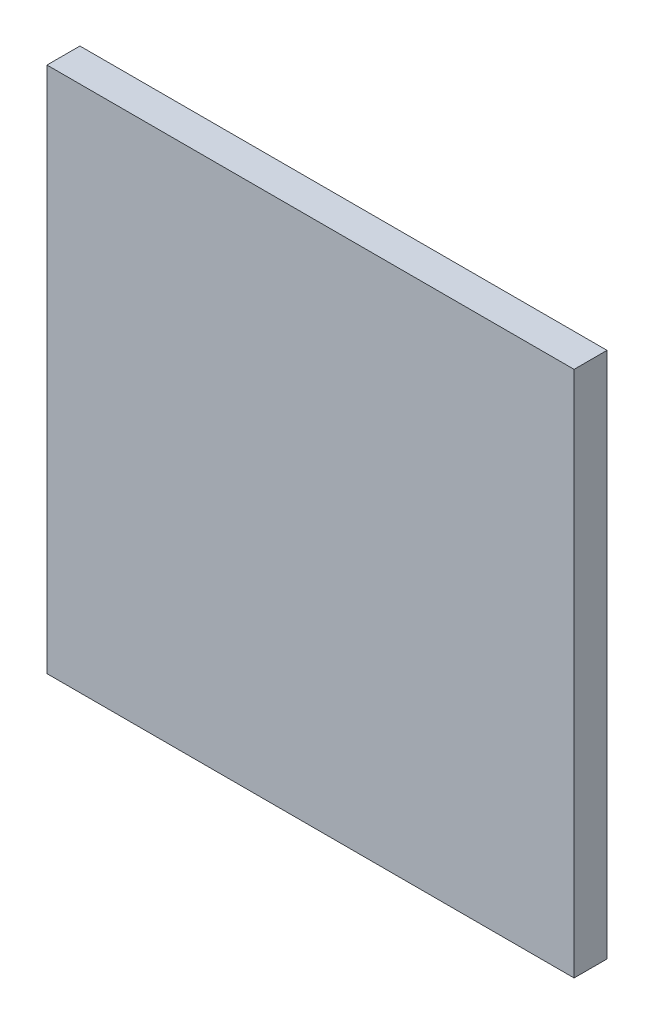
from build123d import *

# Parameters (mm, degrees)
SKETCH1_W           = 40
SKETCH1_H           = 40
BOSS_EXTRUDE1_DEPTH = 2.5


with BuildPart() as part:
    # Sketch1 → Boss-Extrude1 (new body)
    with BuildSketch(Plane.XY):
        Rectangle(SKETCH1_W, SKETCH1_H)
    extrude(amount=BOSS_EXTRUDE1_DEPTH)


solid = part.part
